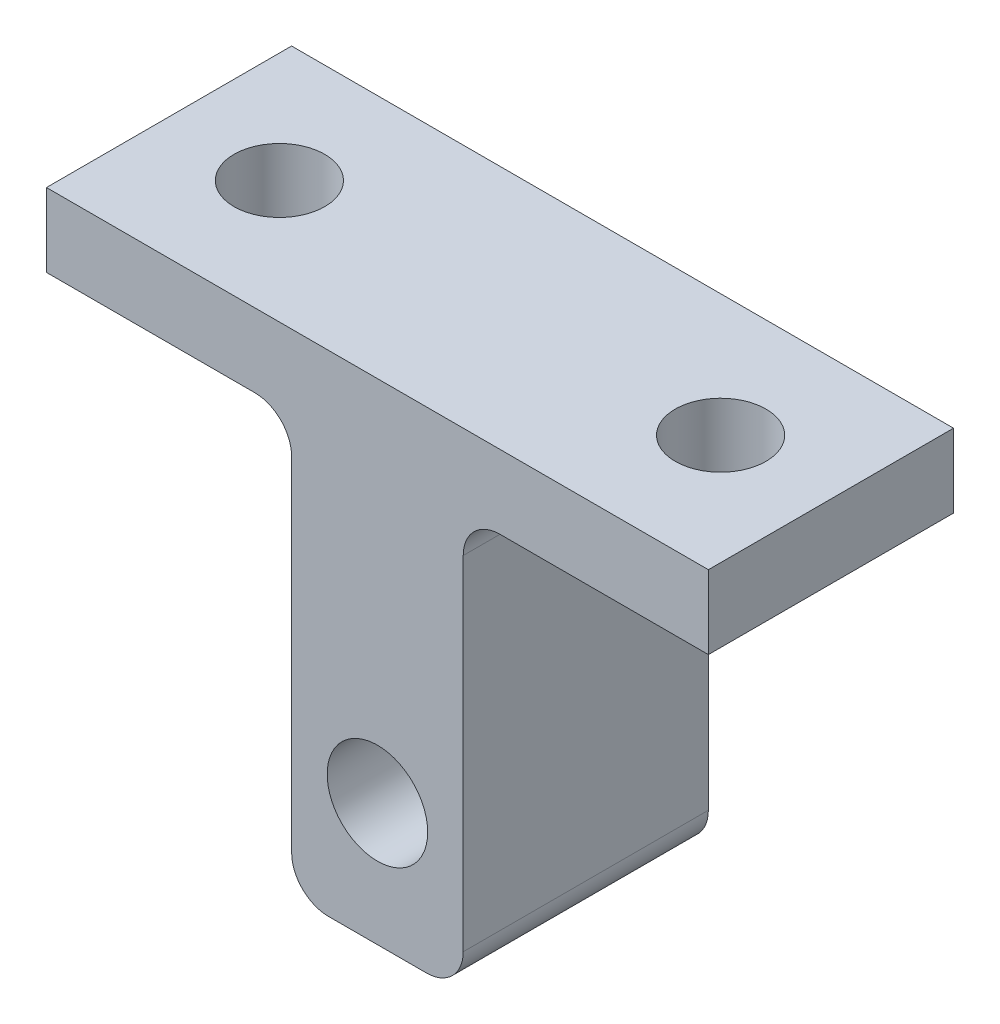
from build123d import *

# Parameters (mm, degrees)
SKETCH1_R           = 2.05
BOSS_EXTRUDE1_DEPTH = 5
FILLET1_R           = 1.5
SKETCH2_R           = 1.85
CUT_EXTRUDE1_DEPTH  = 21


with BuildPart() as part:
    # Sketch1 → Boss-Extrude1 (new body, symmetric)
    with BuildSketch(Plane.XY):
        Polygon((-13.502392344, 0), (-3.5, 0), (-3.5, -17), (3.5, -17), (3.5, 0), (13.502392344, 0), (13.502392344, 3), (-13.502392344, 3), align=None)
        with Locations((0, -12)):
            Circle(SKETCH1_R, mode=Mode.SUBTRACT)
    extrude(amount=BOSS_EXTRUDE1_DEPTH, both=True)

    # Fillet1
    fillet1_edges = [part.edges().sort_by_distance(p)[0] for p in [
        (3.5, 0, 0),
        (3.5, -17, 0),
        (-3.5, -17, 0),
        (-3.5, 0, 0),
    ]]
    fillet(fillet1_edges, radius=FILLET1_R)

    # Sketch2 → Cut-Extrude1 (cut, through all)
    with BuildSketch(Plane(origin=(0, 3, 0), x_dir=(1, 0, 0), z_dir=(0, 1, 0))):
        with Locations((-9, 0)):
            Circle(SKETCH2_R)
        with Locations((9, 0)):
            Circle(SKETCH2_R)
    extrude(amount=-CUT_EXTRUDE1_DEPTH, mode=Mode.SUBTRACT)


solid = part.part
